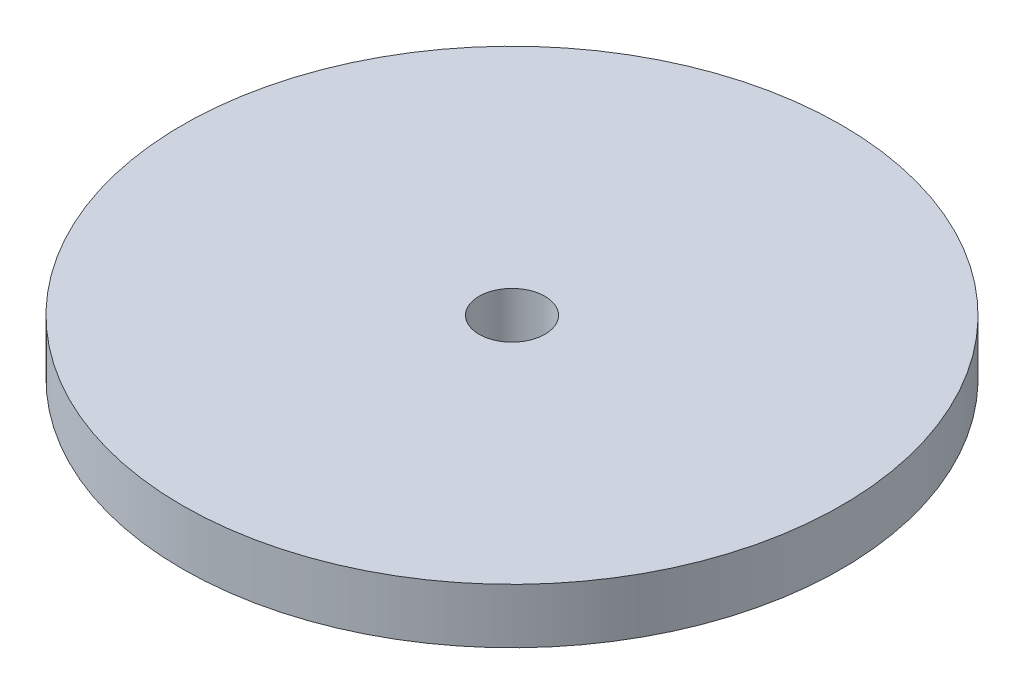
from build123d import *

# Parameters (mm, degrees)
SKETCH1_R           = 30
SKETCH1_R_2         = 3
BOSS_EXTRUDE1_DEPTH = 5


with BuildPart() as part:
    # Sketch1 → Boss-Extrude1 (new body)
    with BuildSketch(Plane(origin=(0, 0, 0), x_dir=(1, 0, 0), z_dir=(0, 1, 0))):
        Circle(SKETCH1_R)
        Circle(SKETCH1_R_2, mode=Mode.SUBTRACT)
    extrude(amount=BOSS_EXTRUDE1_DEPTH)


solid = part.part
